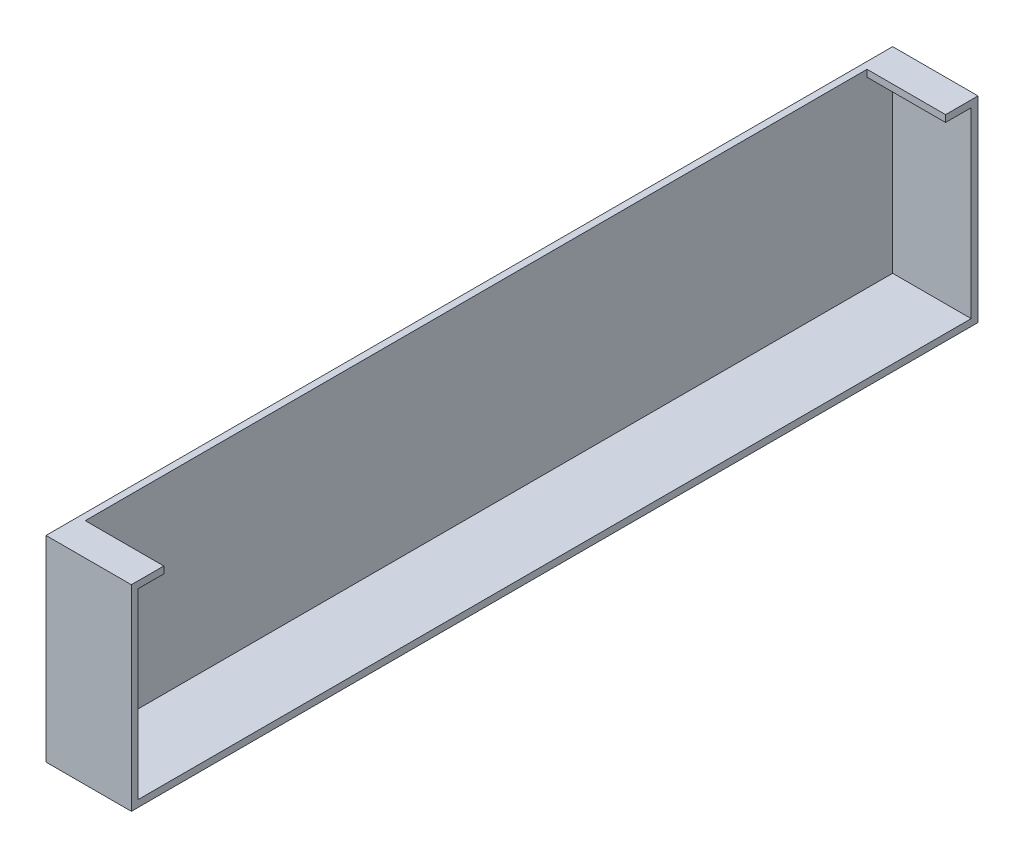
from build123d import *

# Parameters (mm, degrees)
SALIENTE_EXTRUIR1_DEPTH      = 248
SALIENTE_EXTRUIR1_DEPTH_BACK = 248
CROQUIS2_W                   = 50
CROQUIS2_H                   = 115
SALIENTE_EXTRUIR2_DEPTH      = 4
CROQUIS5_W                   = 46
CROQUIS5_H                   = 15
SALIENTE_EXTRUIR5_DEPTH      = 4


with BuildPart() as part:
    # Croquis1 → Saliente-Extruir1 (new, two sides: drawn at the far end of the back side and taken through both)
    with BuildSketch(Plane.XY.offset(-SALIENTE_EXTRUIR1_DEPTH_BACK)):
        Polygon((0, 0), (0, 115), (4, 115), (4, 4), (50, 4), (50, 0), align=None)
    extrude(amount=SALIENTE_EXTRUIR1_DEPTH + SALIENTE_EXTRUIR1_DEPTH_BACK)

    # Croquis2 → Saliente-Extruir2 (add)
    with BuildSketch(Plane.XY.offset(248)):
        with Locations((25, 57.5)):
            Rectangle(CROQUIS2_W, CROQUIS2_H)
    saliente_extruir2 = extrude(amount=-SALIENTE_EXTRUIR2_DEPTH)

    # Simetría1: Saliente-Extruir2 across plane
    add(saliente_extruir2.mirror(Plane.XY))

    # Croquis5 → Saliente-Extruir5 (add)
    with BuildSketch(Plane(origin=(0, 115, 0), x_dir=(1, 0, 0), z_dir=(0, 1, 0))):
        with Locations((27, -236.5)):
            Rectangle(CROQUIS5_W, CROQUIS5_H)
    saliente_extruir5 = extrude(amount=-SALIENTE_EXTRUIR5_DEPTH)

    # Simetría2: Saliente-Extruir5 across plane
    add(saliente_extruir5.mirror(Plane.XY))


solid = part.part
